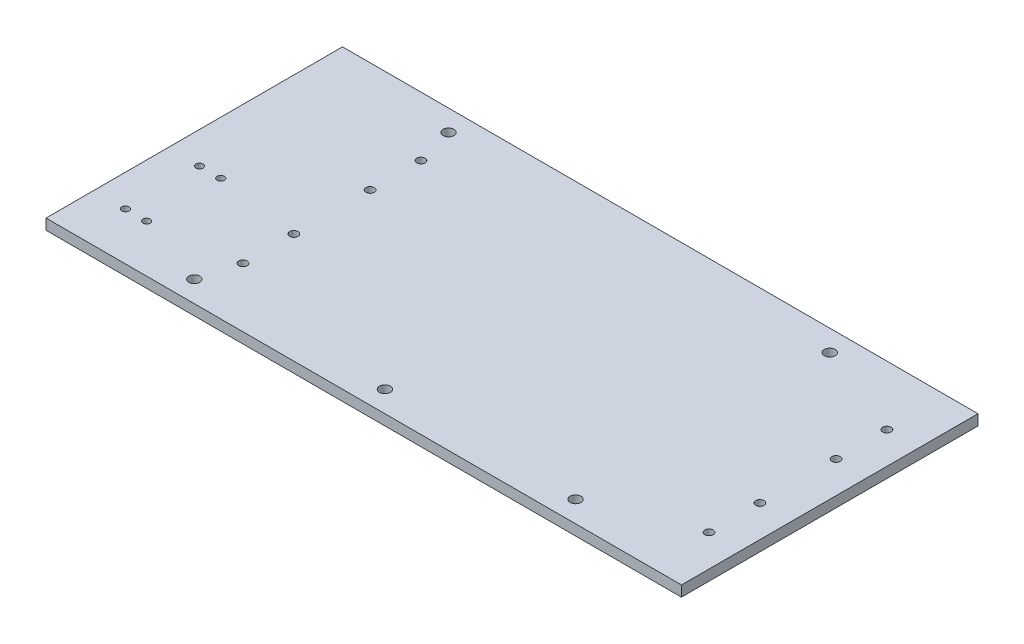
from build123d import *

# Parameters (mm, degrees)
SKETCH1_W                  = 381
SKETCH1_H                  = 177.8
PLATE_DEPTH                = 6.35
SKETCH4_R                  = 3.2639
CHASSISMOUNTINGHOLES_DEPTH = 6.35
SKETCH5_R                  = 2.5019
LEADSCREWGUIDEMOUNTS_DEPTH = 6.35
SKETCH6_R                  = 2.15265
LEADSCREWMOTORMOUNT_DEPTH  = 6.35


with BuildPart() as part:
    # Sketch1 → Plate (new body)
    with BuildSketch(Plane(origin=(0, 0, 0), x_dir=(1, 0, 0), z_dir=(0, 1, 0))):
        Rectangle(SKETCH1_W, SKETCH1_H)
    extrude(amount=PLATE_DEPTH)

    # Sketch4 → ChassisMountingHoles (cut)
    with BuildSketch(Plane.XZ):
        with Locations((0, 76.2)):
            Circle(SKETCH4_R)
        with Locations((-114.3, 76.2)):
            Circle(SKETCH4_R)
        with Locations((114.3, 76.2)):
            Circle(SKETCH4_R)
        with Locations((-114.3, -76.2)):
            Circle(SKETCH4_R)
        with Locations((114.3, -76.2)):
            Circle(SKETCH4_R)
    extrude(amount=-CHASSISMOUNTINGHOLES_DEPTH, mode=Mode.SUBTRACT)

    # Sketch5 → LeadScrewGuideMounts (cut)
    with BuildSketch(Plane.XZ):
        with Locations((171.45, 53.34)):
            Circle(SKETCH5_R)
        with Locations((171.45, 22.86)):
            Circle(SKETCH5_R)
        with Locations((-107.95, 53.34)):
            Circle(SKETCH5_R)
        with Locations((-107.95, 22.86)):
            Circle(SKETCH5_R)
        with Locations((171.45, -53.34)):
            Circle(SKETCH5_R)
        with Locations((171.45, -22.86)):
            Circle(SKETCH5_R)
        with Locations((-107.95, -22.86)):
            Circle(SKETCH5_R)
        with Locations((-107.95, -53.34)):
            Circle(SKETCH5_R)
    extrude(amount=-LEADSCREWGUIDEMOUNTS_DEPTH, mode=Mode.SUBTRACT)

    # Sketch6 → LeadScrewMotorMount (cut)
    with BuildSketch(Plane.XZ):
        with Locations((-171.45, 60.325)):
            Circle(SKETCH6_R)
        with Locations((-158.75, 60.325)):
            Circle(SKETCH6_R)
        with Locations((-171.45, 15.875)):
            Circle(SKETCH6_R)
        with Locations((-158.75, 15.875)):
            Circle(SKETCH6_R)
    extrude(amount=-LEADSCREWMOTORMOUNT_DEPTH, mode=Mode.SUBTRACT)


solid = part.part
